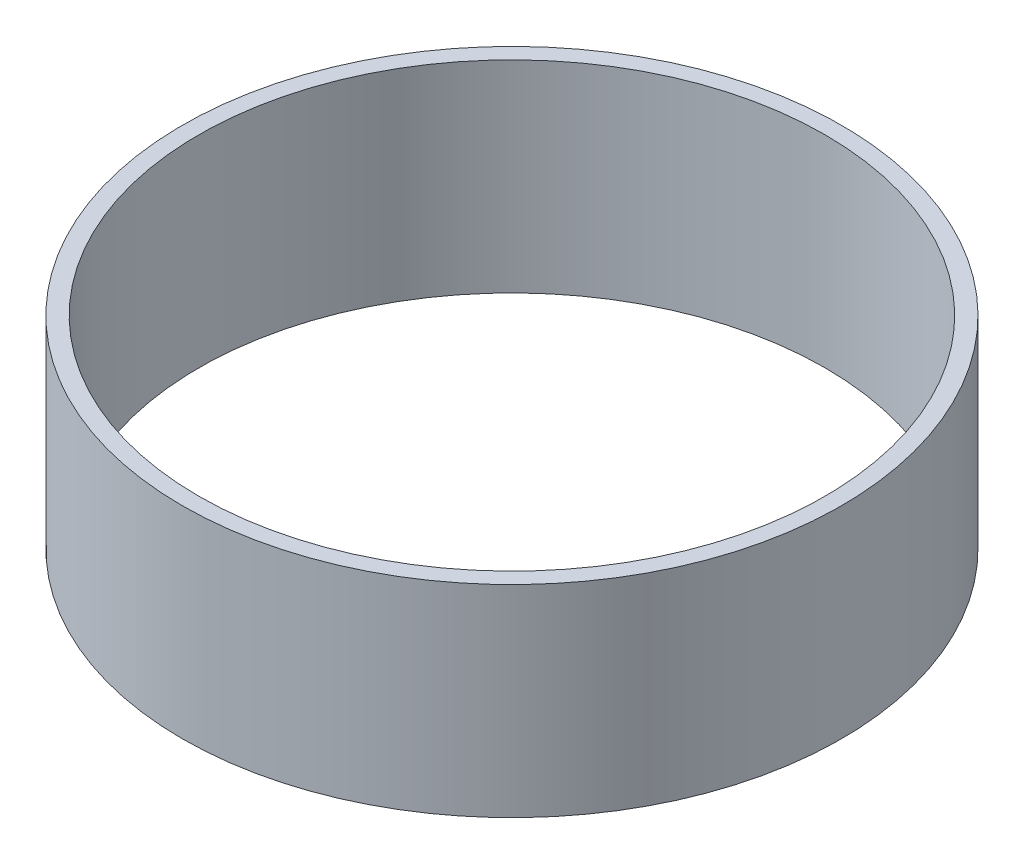
from build123d import *

# Parameters (mm, degrees)
SKETCH_1_R      = 40
SKETCH_1_R_2    = 38
EXTRUDE_1_DEPTH = 24.5


with BuildPart() as part:
    # 草图1 → 凸台-拉伸1 (new body)
    with BuildSketch(Plane(origin=(0, 0, 0), x_dir=(1, 0, 0), z_dir=(0, 1, 0))):
        Circle(SKETCH_1_R)
        Circle(SKETCH_1_R_2, mode=Mode.SUBTRACT)
    extrude(amount=EXTRUDE_1_DEPTH)


solid = part.part
